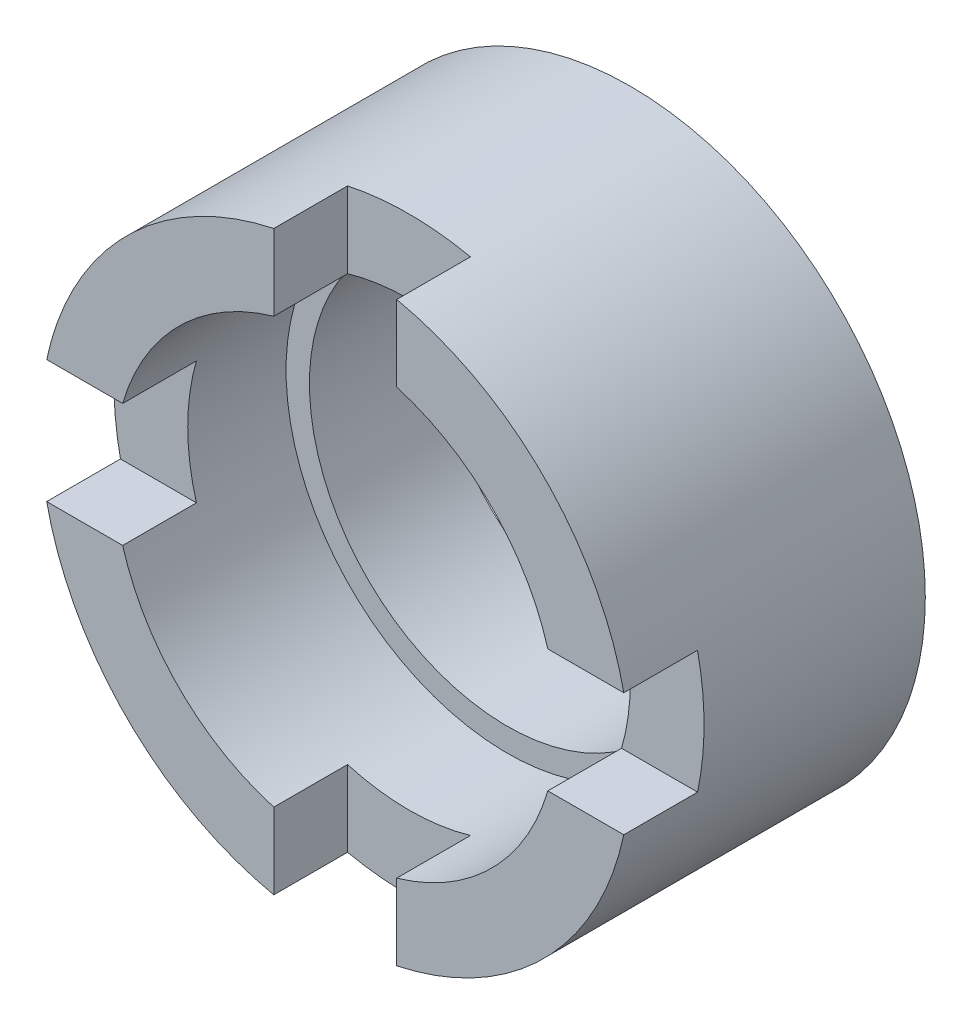
from build123d import *

# Parameters (mm, degrees)
SKETCH_1_R          = 12
SKETCH_1_R_2        = 8.05
EXTRUDE_1_DEPTH     = 12
CUT_EXTRUDE_1_DEPTH = 3
SKETCH_4_R          = 9
CUT_EXTRUDE_2_DEPTH = 7


with BuildPart() as part:
    # 草图1 → 凸台-拉伸1 (new body)
    with BuildSketch(Plane.XY):
        Circle(SKETCH_1_R)
        Circle(SKETCH_1_R_2, mode=Mode.SUBTRACT)
    extrude(amount=EXTRUDE_1_DEPTH)

    # 草图3 → 切除-拉伸1 (cut)
    with BuildSketch(Plane.XY.offset(12)):
        Polygon((-16.5, 2.5), (-2.5, 2.5), (-2.5, 16.5), (2.5, 16.5), (2.5, 2.5), (16.5, 2.5), (16.5, -2.5), (2.5, -2.5), (2.5, -16.5), (-2.5, -16.5), (-2.5, -2.5), (-16.5, -2.5), align=None)
    extrude(amount=-CUT_EXTRUDE_1_DEPTH, mode=Mode.SUBTRACT)

    # 草图4 → 切除-拉伸2 (cut)
    with BuildSketch(Plane.XY.offset(12)):
        Circle(SKETCH_4_R)
    extrude(amount=-CUT_EXTRUDE_2_DEPTH, mode=Mode.SUBTRACT)


solid = part.part
